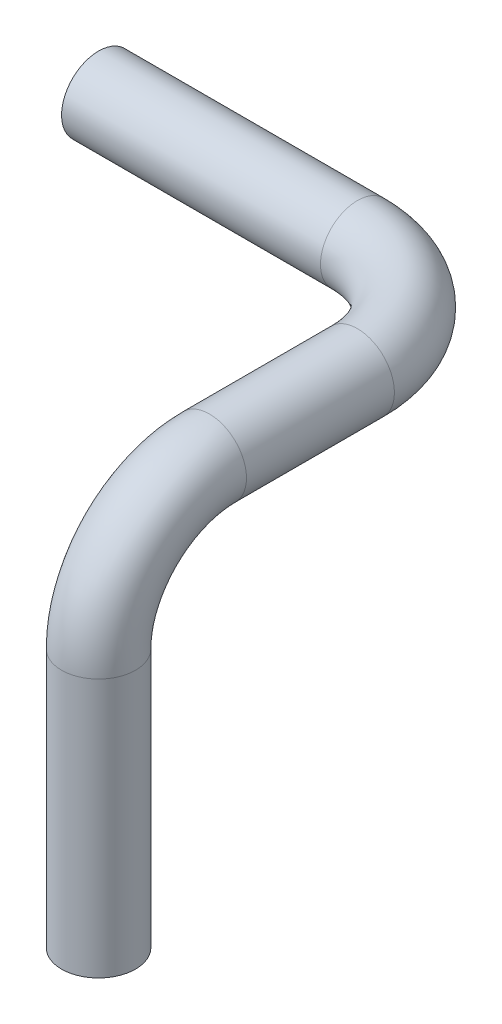
from build123d import *

# Parameters (mm, degrees)
SWEEP1_PROFILE_R = 25.4
SHELL1_T         = -2.54


with BuildPart() as part:
    # Sweep1: sweep along a curve in space
    with BuildLine() as sweep1_path:
        Line((0, 254, 0), (177.8, 254, 0))
        ThreePointArc((177.8, 254, 0), (231.681536726, 254, 22.318463274), (254, 254, 76.2))
        Line((254, 254, 76.2), (254, 254, 177.8))
        ThreePointArc((254, 254, 177.8), (254, 231.681536726, 231.681536726), (254, 177.8, 254))
        Line((254, 177.8, 254), (254, 0, 254))
    # Sweep1 profile (on start of the path) → Sweep1 (sweep)
    with BuildSketch(Plane(origin=(0, 254, 0), x_dir=(0, 0, 1), z_dir=(1, 0, 0))):
        Circle(SWEEP1_PROFILE_R)
    sweep(path=sweep1_path.line)

    # Shell1
    shell1_openings = [part.faces().sort_by_distance(p)[0] for p in [
        (254, 0, 254),
        (0, 254, 0),
    ]]
    offset(amount=SHELL1_T, openings=shell1_openings, kind=Kind.INTERSECTION)


solid = part.part
